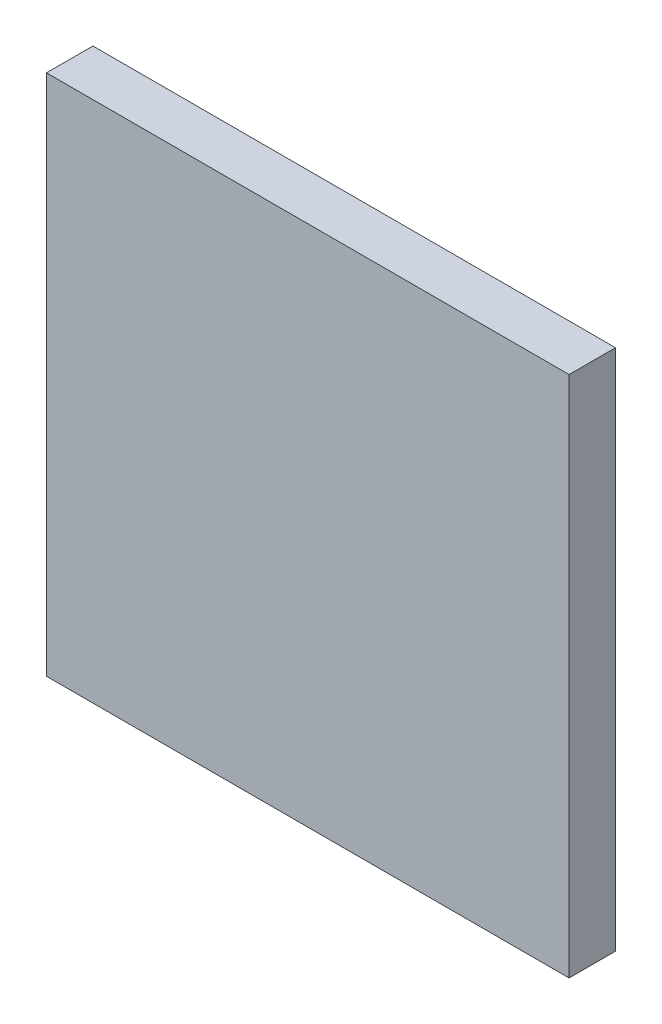
from build123d import *

# Parameters (mm, degrees)
SKETCH1_W           = 45
SKETCH1_H           = 45
BOSS_EXTRUDE1_DEPTH = 4


with BuildPart() as part:
    # Sketch1 → Boss-Extrude1 (new body)
    with BuildSketch(Plane.XY):
        with Locations((22.5, 22.5)):
            Rectangle(SKETCH1_W, SKETCH1_H)
    extrude(amount=BOSS_EXTRUDE1_DEPTH)


solid = part.part
